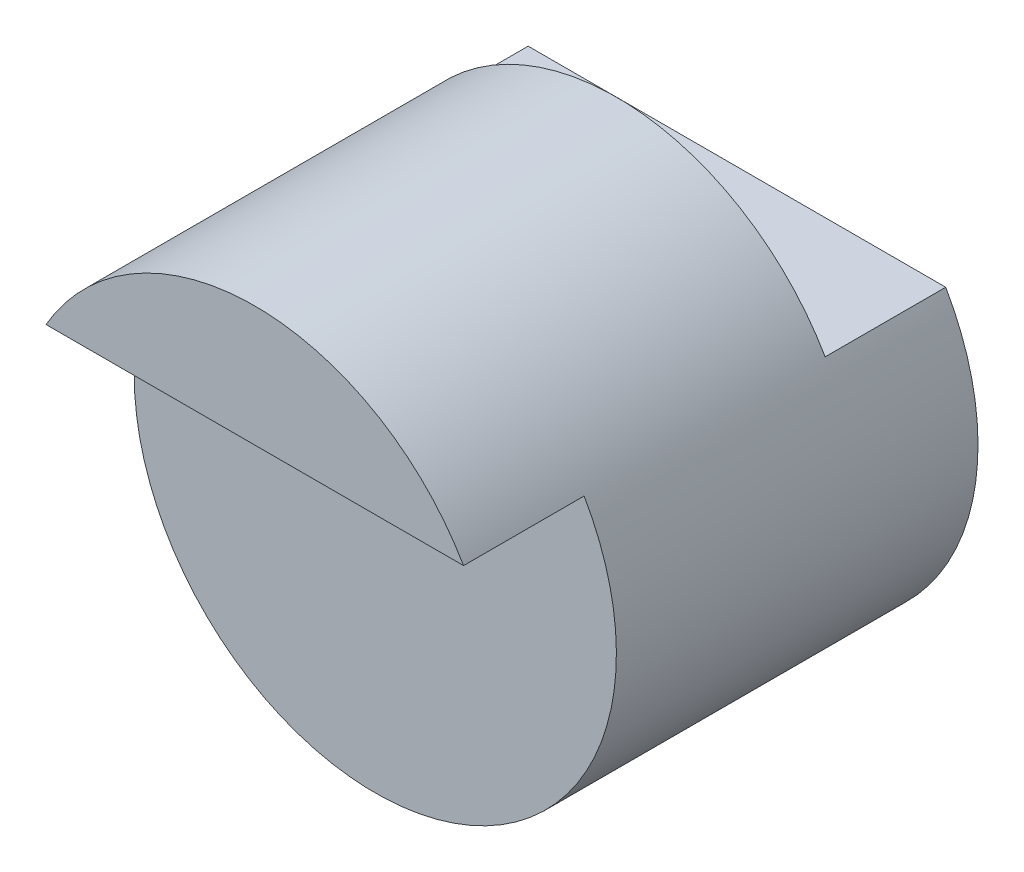
from build123d import *

# Parameters (mm, degrees)
SKETCH1_R           = 2
BOSS_EXTRUDE1_DEPTH = 3
BOSS_EXTRUDE2_DEPTH = 1
CUT_EXTRUDE1_DEPTH  = 1


with BuildPart() as part:
    # Sketch1 → Boss-Extrude1 (new body)
    with BuildSketch(Plane.XY):
        Circle(SKETCH1_R)
    extrude(amount=BOSS_EXTRUDE1_DEPTH)

    # Sketch2 → Boss-Extrude2 (add)
    with BuildSketch(Plane.XY.offset(3)):
        with BuildLine():
            Line((-1.732050808, 1), (1.732050808, 1))
            ThreePointArc((1.732050808, 1), (0, 2), (-1.732050808, 1))
        make_face()
    extrude(amount=BOSS_EXTRUDE2_DEPTH)

    # Sketch3 → Cut-Extrude1 (cut)
    with BuildSketch(Plane(origin=(0, 0, 0), x_dir=(-1, 0, 0), z_dir=(0, 0, -1))):
        with BuildLine():
            Line((1.732050808, 1), (-1.732050808, 1))
            ThreePointArc((-1.732050808, 1), (0, 2), (1.732050808, 1))
        make_face()
    extrude(amount=-CUT_EXTRUDE1_DEPTH, mode=Mode.SUBTRACT)


solid = part.part
